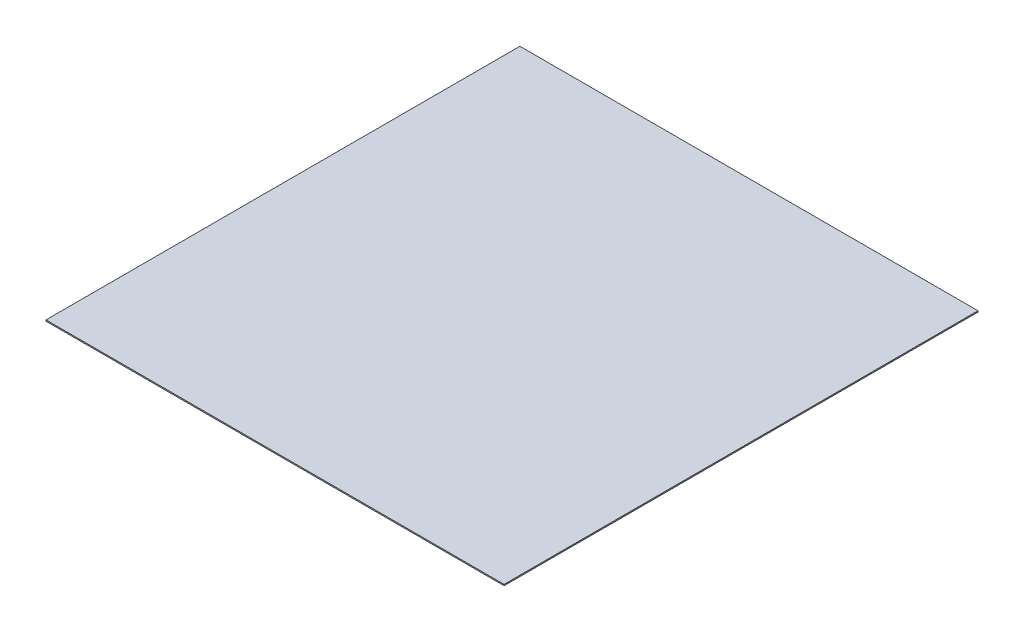
from build123d import *

# Parameters (mm, degrees)
SKETCH1_W      = 19.2096
SKETCH1_H      = 19.872
EXTRUDE1_DEPTH = 0.05


with BuildPart() as part:
    # Sketch1 → Extrude1 (new body)
    with BuildSketch(Plane(origin=(0, 0, 0), x_dir=(1, 0, 0), z_dir=(0, 1, 0))):
        Rectangle(SKETCH1_W, SKETCH1_H)
    extrude(amount=EXTRUDE1_DEPTH)


solid = part.part
